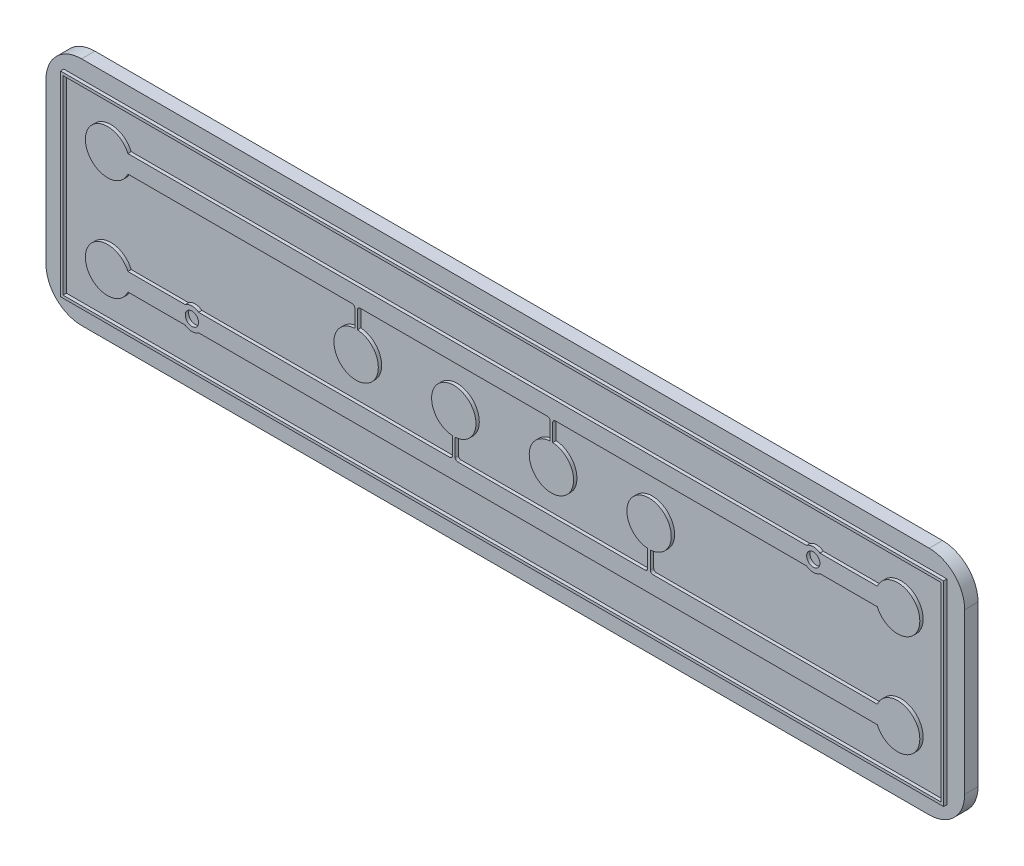
from build123d import *

# Parameters (mm, degrees)
SKETCH1_W             = 98.893995825
SKETCH1_H             = 21.421924981
BOSS_EXTRUDE1_DEPTH   = 1.5
SKETCH1_R             = 0.75
BOSS_EXTRUDE1_2_DEPTH = 1.5
BOSS_EXTRUDE1_3_DEPTH = 1.5
SKETCH1_9_R           = 0.75
BOSS_EXTRUDE2_DEPTH   = 1.875
SKETCH1_10_W          = 99.493995825
SKETCH1_10_H          = 22.021924981
SKETCH1_10_W_2        = 98.893995825
SKETCH1_10_H_2        = 21.421924981
BOSS_EXTRUDE3_DEPTH   = 1.875
SKETCH1_11_W          = 99.493995825
SKETCH1_11_H          = 22.021924981
BOSS_EXTRUDE4_DEPTH   = 1.5


with BuildPart() as part:
    # Sketch1 → Boss-Extrude1 (new body)
    with BuildSketch(Plane.XY):
        with Locations((-3.702524559, 8.286725718)):
            Rectangle(SKETCH1_W, SKETCH1_H)
        with BuildLine():
            ThreePointArc((2.011897659, 12.737688209), (2.099765624, 12.949820243), (2.311897659, 13.037688209))
            Line((2.311897659, 13.037688209), (30.614473354, 13.037688209))
            ThreePointArc((30.614473354, 13.037688209), (31.364473354, 12.787688209), (32.114473354, 13.037688209))
            Line((32.114473354, 13.037688209), (38.573185506, 13.037688209))
            ThreePointArc((38.573185506, 13.037688209), (43.364473354, 14.037688209), (38.573185506, 15.037688209))
            Line((38.573185506, 15.037688209), (32.114473354, 15.037688209))
            ThreePointArc((32.114473354, 15.037688209), (31.364473354, 15.287688209), (30.614473354, 15.037688209))
            Line((30.614473354, 15.037688209), (-45.846814494, 15.037688209))
            ThreePointArc((-45.846814494, 15.037688209), (-50.638102341, 14.037688209), (-45.846814494, 13.037688209))
            Line((-45.846814494, 13.037688209), (-20.588102341, 13.037688209))
            ThreePointArc((-20.588102341, 13.037688209), (-20.375970307, 12.949820243), (-20.288102341, 12.737688209))
            Line((-20.288102341, 12.737688209), (-20.288102341, 10.774606087))
            ThreePointArc((-20.288102341, 10.774606087), (-20.138102341, 5.779110144), (-19.988102341, 10.774606087))
            Line((-19.988102341, 10.774606087), (-19.988102341, 12.737688209))
            ThreePointArc((-19.988102341, 12.737688209), (-19.900234376, 12.949820243), (-19.688102341, 13.037688209))
            Line((-19.688102341, 13.037688209), (1.411897659, 13.037688209))
            ThreePointArc((1.411897659, 13.037688209), (1.624029693, 12.949820243), (1.711897659, 12.737688209))
            Line((1.711897659, 12.737688209), (1.711897659, 10.774606087))
            ThreePointArc((1.711897659, 10.774606087), (1.861897659, 5.779110144), (2.011897659, 10.774606087))
            Line((2.011897659, 10.774606087), (2.011897659, 12.737688209))
        make_face(mode=Mode.SUBTRACT)
        with BuildLine():
            Line((13.014473354, 3.832527843), (13.014473354, 5.795609965))
            ThreePointArc((13.014473354, 5.795609965), (12.864473354, 10.791105907), (12.714473354, 5.795609965))
            Line((12.714473354, 5.795609965), (12.714473354, 3.832527843))
            ThreePointArc((12.714473354, 3.832527843), (12.626605388, 3.620395809), (12.414473354, 3.532527843))
            Line((12.414473354, 3.532527843), (-8.685526646, 3.532527843))
            ThreePointArc((-8.685526646, 3.532527843), (-8.897658681, 3.620395809), (-8.985526646, 3.832527843))
            Line((-8.985526646, 3.832527843), (-8.985526646, 5.795609965))
            ThreePointArc((-8.985526646, 5.795609965), (-9.135526646, 10.791105907), (-9.285526646, 5.795609965))
            Line((-9.285526646, 5.795609965), (-9.285526646, 3.832527843))
            ThreePointArc((-9.285526646, 3.832527843), (-9.373394612, 3.620395809), (-9.585526646, 3.532527843))
            Line((-9.585526646, 3.532527843), (-37.888102341, 3.532527843))
            ThreePointArc((-37.888102341, 3.532527843), (-38.638102341, 3.782527843), (-39.388102341, 3.532527843))
            Line((-39.388102341, 3.532527843), (-45.846814494, 3.532527843))
            ThreePointArc((-45.846814494, 3.532527843), (-50.638102341, 2.532527843), (-45.846814494, 1.532527843))
            Line((-45.846814494, 1.532527843), (-39.388102341, 1.532527843))
            ThreePointArc((-39.388102341, 1.532527843), (-38.638102341, 1.282527843), (-37.888102341, 1.532527843))
            Line((-37.888102341, 1.532527843), (38.573185506, 1.532527843))
            ThreePointArc((38.573185506, 1.532527843), (43.364473354, 2.532527843), (38.573185506, 3.532527843))
            Line((38.573185506, 3.532527843), (13.314473354, 3.532527843))
            ThreePointArc((13.314473354, 3.532527843), (13.102341319, 3.620395809), (13.014473354, 3.832527843))
        make_face(mode=Mode.SUBTRACT)
    extrude(amount=BOSS_EXTRUDE1_DEPTH)



with BuildPart() as body_2:
    # Sketch1 → Boss-Extrude1 2 (new body)
    with BuildSketch(Plane.XY):
        with Locations((31.364473354, 14.037688209)):
            Circle(SKETCH1_R)
    extrude(amount=BOSS_EXTRUDE1_2_DEPTH)


with BuildPart() as body_3:
    # Sketch1 → Boss-Extrude1 3 (new body)
    with BuildSketch(Plane.XY):
        with Locations((-38.638102341, 2.532527843)):
            Circle(SKETCH1_R)
    extrude(amount=BOSS_EXTRUDE1_3_DEPTH)


with BuildPart() as part_1:
    add(part.part)

    add(body_2.part)  # Boss-Extrude2 merges body 2

    add(body_3.part)  # Boss-Extrude2 merges body 3
    # Sketch1_9 → Boss-Extrude2 (add)
    with BuildSketch(Plane.XY):
        with BuildLine():
            Line((2.011897659, 12.737688209), (2.011897659, 10.774606087))
            ThreePointArc((2.011897659, 10.774606087), (1.861897659, 5.779110144), (1.711897659, 10.774606087))
            Line((1.711897659, 10.774606087), (1.711897659, 12.737688209))
            ThreePointArc((1.711897659, 12.737688209), (1.624029693, 12.949820243), (1.411897659, 13.037688209))
            Line((1.411897659, 13.037688209), (-19.688102341, 13.037688209))
            ThreePointArc((-19.688102341, 13.037688209), (-19.900234376, 12.949820243), (-19.988102341, 12.737688209))
            Line((-19.988102341, 12.737688209), (-19.988102341, 10.774606087))
            ThreePointArc((-19.988102341, 10.774606087), (-20.138102341, 5.779110144), (-20.288102341, 10.774606087))
            Line((-20.288102341, 10.774606087), (-20.288102341, 12.737688209))
            ThreePointArc((-20.288102341, 12.737688209), (-20.375970307, 12.949820243), (-20.588102341, 13.037688209))
            Line((-20.588102341, 13.037688209), (-45.846814494, 13.037688209))
            ThreePointArc((-45.846814494, 13.037688209), (-50.638102341, 14.037688209), (-45.846814494, 15.037688209))
            Line((-45.846814494, 15.037688209), (30.614473354, 15.037688209))
            ThreePointArc((30.614473354, 15.037688209), (31.364473354, 15.287688209), (32.114473354, 15.037688209))
            Line((32.114473354, 15.037688209), (38.573185506, 15.037688209))
            ThreePointArc((38.573185506, 15.037688209), (43.364473354, 14.037688209), (38.573185506, 13.037688209))
            Line((38.573185506, 13.037688209), (32.114473354, 13.037688209))
            ThreePointArc((32.114473354, 13.037688209), (31.364473354, 12.787688209), (30.614473354, 13.037688209))
            Line((30.614473354, 13.037688209), (2.311897659, 13.037688209))
            ThreePointArc((2.311897659, 13.037688209), (2.099765624, 12.949820243), (2.011897659, 12.737688209))
        make_face()
        with Locations((31.364473354, 14.037688209)):
            Circle(SKETCH1_9_R, mode=Mode.SUBTRACT)
        with BuildLine():
            ThreePointArc((13.014473354, 3.832527843), (13.102341319, 3.620395809), (13.314473354, 3.532527843))
            Line((13.314473354, 3.532527843), (38.573185506, 3.532527843))
            ThreePointArc((38.573185506, 3.532527843), (43.364473354, 2.532527843), (38.573185506, 1.532527843))
            Line((38.573185506, 1.532527843), (-37.888102341, 1.532527843))
            ThreePointArc((-37.888102341, 1.532527843), (-38.638102341, 1.282527843), (-39.388102341, 1.532527843))
            Line((-39.388102341, 1.532527843), (-45.846814494, 1.532527843))
            ThreePointArc((-45.846814494, 1.532527843), (-50.638102341, 2.532527843), (-45.846814494, 3.532527843))
            Line((-45.846814494, 3.532527843), (-39.388102341, 3.532527843))
            ThreePointArc((-39.388102341, 3.532527843), (-38.638102341, 3.782527843), (-37.888102341, 3.532527843))
            Line((-37.888102341, 3.532527843), (-9.585526646, 3.532527843))
            ThreePointArc((-9.585526646, 3.532527843), (-9.373394612, 3.620395809), (-9.285526646, 3.832527843))
            Line((-9.285526646, 3.832527843), (-9.285526646, 5.795609965))
            ThreePointArc((-9.285526646, 5.795609965), (-9.135526646, 10.791105907), (-8.985526646, 5.795609965))
            Line((-8.985526646, 5.795609965), (-8.985526646, 3.832527843))
            ThreePointArc((-8.985526646, 3.832527843), (-8.897658681, 3.620395809), (-8.685526646, 3.532527843))
            Line((-8.685526646, 3.532527843), (12.414473354, 3.532527843))
            ThreePointArc((12.414473354, 3.532527843), (12.626605388, 3.620395809), (12.714473354, 3.832527843))
            Line((12.714473354, 3.832527843), (12.714473354, 5.795609965))
            ThreePointArc((12.714473354, 5.795609965), (12.864473354, 10.791105907), (13.014473354, 5.795609965))
            Line((13.014473354, 5.795609965), (13.014473354, 3.832527843))
        make_face()
        with Locations((-38.638102341, 2.532527843)):
            Circle(SKETCH1_9_R, mode=Mode.SUBTRACT)
    extrude(amount=BOSS_EXTRUDE2_DEPTH)

    # Sketch1_10 → Boss-Extrude3 (add)
    with BuildSketch(Plane.XY):
        with Locations((-3.702524558, 8.286725718)):
            Rectangle(SKETCH1_10_W, SKETCH1_10_H)
        with Locations((-3.702524559, 8.286725718)):
            Rectangle(SKETCH1_10_W_2, SKETCH1_10_H_2, mode=Mode.SUBTRACT)
    extrude(amount=BOSS_EXTRUDE3_DEPTH)

    # Sketch1_11 → Boss-Extrude4 (add)
    with BuildSketch(Plane.XY):
        with BuildLine():
            ThreePointArc((-55.449522471, 17.297688209), (-54.277949596, 20.126115333), (-51.449522471, 21.297688209))
            Line((-51.449522471, 21.297688209), (44.044473354, 21.297688209))
            ThreePointArc((44.044473354, 21.297688209), (46.872900478, 20.126115333), (48.044473354, 17.297688209))
            Line((48.044473354, 17.297688209), (48.044473354, -0.724236772))
            ThreePointArc((48.044473354, -0.724236772), (46.872900478, -3.552663897), (44.044473354, -4.724236772))
            Line((44.044473354, -4.724236772), (-51.449522471, -4.724236772))
            ThreePointArc((-51.449522471, -4.724236772), (-54.277949596, -3.552663897), (-55.449522471, -0.724236772))
            Line((-55.449522471, -0.724236772), (-55.449522471, 17.297688209))
        make_face()
        with Locations((-3.702524558, 8.286725718)):
            Rectangle(SKETCH1_11_W, SKETCH1_11_H, mode=Mode.SUBTRACT)
    extrude(amount=BOSS_EXTRUDE4_DEPTH)


solid = part_1.part
